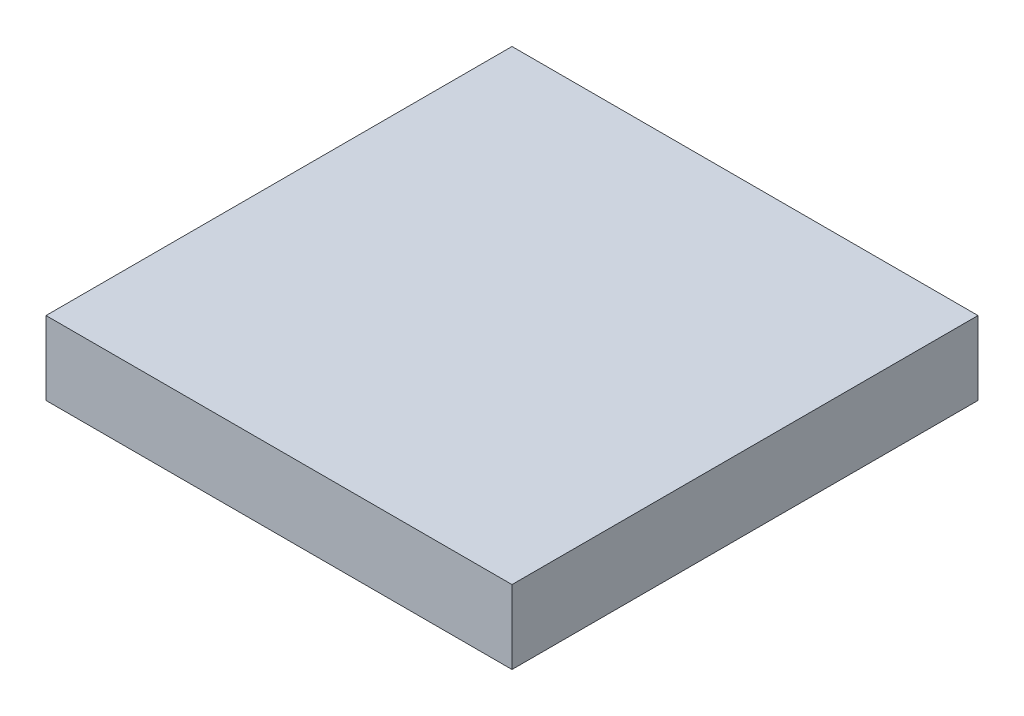
from build123d import *

# Parameters (mm, degrees)
SKETCH1_W           = 90
SKETCH1_H           = 95
BOSS_EXTRUDE3_DEPTH = 15
SKETCH5_W           = 15
SKETCH5_H           = 8.4
CUT_EXTRUDE3_DEPTH  = 40
SKETCH7_W           = 95
SKETCH7_H           = 15
BOSS_EXTRUDE4_DEPTH = 5


with BuildPart() as part:
    # Sketch1 → Boss-Extrude3 (new body)
    with BuildSketch(Plane(origin=(0, 0, 0), x_dir=(1, 0, 0), z_dir=(0, 1, 0))):
        Rectangle(SKETCH1_W, SKETCH1_H)
    extrude(amount=BOSS_EXTRUDE3_DEPTH)

    # Sketch5 → Cut-Extrude3 (cut)
    with BuildSketch(Plane(origin=(45, 0, 0), x_dir=(0, 0, -1), z_dir=(1, 0, 0))):
        with Locations((0.9, 6.2)):
            Rectangle(SKETCH5_W, SKETCH5_H)
    extrude(amount=-CUT_EXTRUDE3_DEPTH, mode=Mode.SUBTRACT)

    # Sketch7 → Boss-Extrude4 (add)
    with BuildSketch(Plane(origin=(45, 0, 0), x_dir=(0, 0, -1), z_dir=(1, 0, 0))):
        with Locations((0, 7.5)):
            Rectangle(SKETCH7_W, SKETCH7_H)
    extrude(amount=BOSS_EXTRUDE4_DEPTH)


solid = part.part
